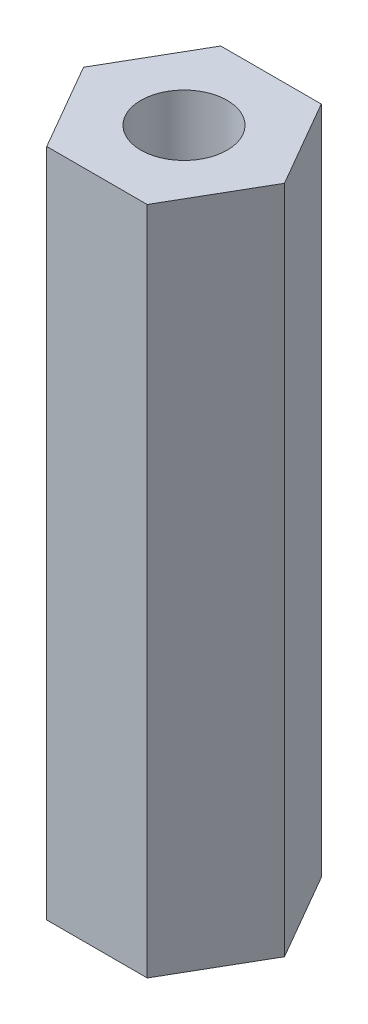
from build123d import *

# Parameters (mm, degrees)
BOSS_EXTRUDE1_DEPTH             = 30
F_5_40_TAPPED_HOLE1_D           = 2.5781
F_5_40_TAPPED_HOLE1_DEPTH       = 15
F_5_40_TAPPED_HOLE1_CSINK_D     = 4.445
F_5_40_TAPPED_HOLE1_CSINK_ANGLE = 100
F_5_40_TAPPED_HOLE1_TIP         = 0.774539381
M4X0_7_TAPPED_HOLE1_D           = 3.3
M4X0_7_TAPPED_HOLE1_DEPTH       = 15
M4X0_7_TAPPED_HOLE1_TIP         = 0.991420021
SKETCH9_R                       = 3
CUT_EXTRUDE2_DEPTH              = 5
SKETCH10_R                      = 3
CUT_EXTRUDE3_DEPTH              = 5


with BuildPart() as part:
    # Sketch2 → Boss-Extrude1 (new body)
    with BuildSketch(Plane(origin=(0, 0, 0), x_dir=(1, 0, 0), z_dir=(0, 1, 0))):
        Polygon((3, 0), (1.5, 2.598076211), (-1.5, 2.598076211), (-3, 0), (-1.5, -2.598076211), (1.5, -2.598076211), align=None)
    extrude(amount=BOSS_EXTRUDE1_DEPTH)

    # #5-40 Tapped Hole1
    with Locations(Plane(origin=(0, 30, 0), x_dir=(1, 0, 0), z_dir=(0, 1, 0))):
        with Locations((0, 0)):
            CounterSinkHole(F_5_40_TAPPED_HOLE1_D / 2, F_5_40_TAPPED_HOLE1_CSINK_D / 2, depth=F_5_40_TAPPED_HOLE1_DEPTH, counter_sink_angle=F_5_40_TAPPED_HOLE1_CSINK_ANGLE)
            with Locations((0, 0, -(F_5_40_TAPPED_HOLE1_DEPTH + F_5_40_TAPPED_HOLE1_TIP / 2))):  # 118° drill point
                Cone(0, F_5_40_TAPPED_HOLE1_D / 2, F_5_40_TAPPED_HOLE1_TIP, mode=Mode.SUBTRACT)

    # M4x0.7 Tapped Hole1
    with Locations(Plane(origin=(-0.014516339, 0, -0.025143037), x_dir=(0, 0, -1), z_dir=(0, -1, 0))):
        with Locations((0, 0)):
            Hole(M4X0_7_TAPPED_HOLE1_D / 2, depth=M4X0_7_TAPPED_HOLE1_DEPTH)
            with Locations((0, 0, -(M4X0_7_TAPPED_HOLE1_DEPTH + M4X0_7_TAPPED_HOLE1_TIP / 2))):  # 118° drill point
                Cone(0, M4X0_7_TAPPED_HOLE1_D / 2, M4X0_7_TAPPED_HOLE1_TIP, mode=Mode.SUBTRACT)

    # Sketch9 → Cut-Extrude2 (cut)
    with BuildSketch(Plane(origin=(0, 30, 0), x_dir=(1, 0, 0), z_dir=(0, 1, 0))):
        Circle(SKETCH9_R)
    extrude(amount=-CUT_EXTRUDE2_DEPTH, mode=Mode.SUBTRACT)

    # Sketch10 → Cut-Extrude3 (cut)
    with BuildSketch(Plane.XZ):
        Circle(SKETCH10_R)
    extrude(amount=-CUT_EXTRUDE3_DEPTH, mode=Mode.SUBTRACT)


solid = part.part
